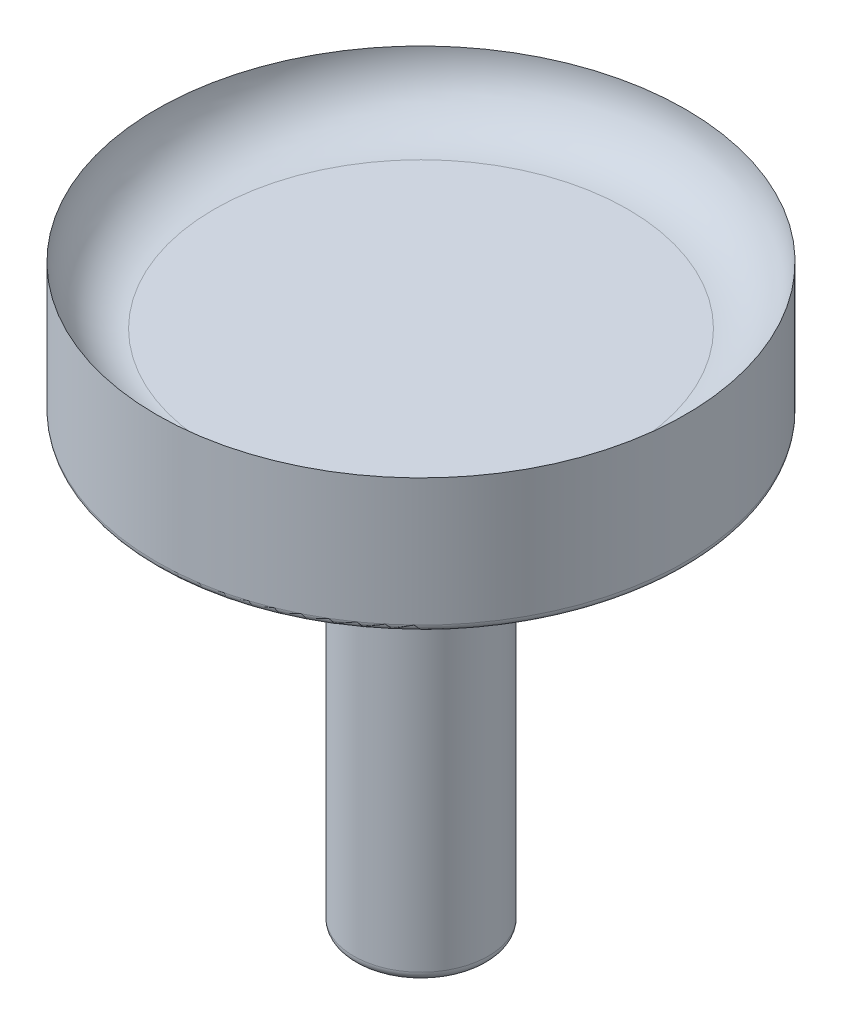
from build123d import *
from build123d.topology import SkipClean

# Parameters (mm, degrees)
CUT_EXTRUDE1_START = 10
CUT_EXTRUDE1_DEPTH = 10
CUT_EXTRUDE2_DEPTH = 70


with BuildPart() as part:
    # Sketch1 → Revolve1 (revolve)
    with BuildSketch(Plane.XY, mode=Mode.PRIVATE) as revolve1_sk:
        with BuildLine():
            Line((-55, 0), (-55, 17.999999999999996))
            ThreePointArc((-55, 17.999999999999996), (-51.48528137423857, 9.514718625761427), (-43, 5.999999999999995))
            Line((-43, 5.999999999999995), (0, 5.999999999999995))
            Line((0, 5.999999999999995), (0, 0))
            Line((0, 0), (0, -2.0000000000000058))
            Line((0, -2.0000000000000058), (-4, -2.000000000000007))
            ThreePointArc((-4, -2.000000000000007), (-8.242640687119284, -3.7573593128807214), (-10.000000000000002, -8.000000000000007))
            Line((-10.000000000000002, -8.000000000000007), (-10.000000000000002, -36.00000000000001))
            ThreePointArc((-10.000000000000002, -36.00000000000001), (-8.242640687119287, -40.24264068711929), (-4, -42.00000000000001))
            Line((-4, -42.00000000000001), (0, -42.00000000000001))
            Line((0, -42.00000000000001), (0, -46.000000000000014))
            Line((0, -46.000000000000014), (-4, -46.000000000000014))
            ThreePointArc((-4, -46.000000000000014), (-8.242640687119284, -47.75735931288073), (-10.000000000000002, -52.000000000000014))
            Line((-10.000000000000002, -52.000000000000014), (-10, -80))
            ThreePointArc((-10, -80), (-8.242640687119286, -84.24264068711929), (-4, -86))
            Line((-4, -86), (4.9e-16, -86))
            Line((4.9e-16, -86), (9.8e-16, -90.00000000000001))
            Line((9.8e-16, -90.00000000000001), (-4.000000000000001, -90.00000000000001))
            ThreePointArc((-4.000000000000001, -90.00000000000001), (-8.242640687119284, -91.75735931288072), (-10, -96.00000000000001))
            Line((-10, -96.00000000000001), (-9.999999999999988, -99.99999999999989))
            ThreePointArc((-9.999999999999988, -99.99999999999989), (-11.999999999999988, -101.99999999999989), (-13.999999999999988, -99.99999999999989))
            Line((-13.999999999999988, -99.99999999999989), (-14, -2.7500000000000058))
            ThreePointArc((-14, -2.7500000000000058), (-14.219669914110089, -2.2196699141100953), (-14.75, -2.0000000000000058))
            Line((-14.75, -2.0000000000000058), (-45.00000000000001, -2.0000000000000053))
            ThreePointArc((-45.00000000000001, -2.0000000000000053), (-49.24264068711929, -3.7573593128807197), (-51.00000000000001, -8.000000000000005))
            Line((-51.00000000000001, -8.000000000000005), (-51.00000000000001, -8.500000000000007))
            ThreePointArc((-51.00000000000001, -8.500000000000007), (-51.439339828220184, -9.560660171779826), (-52.50000000000001, -10.000000000000005))
            Line((-52.50000000000001, -10.000000000000005), (-53.5, -10.000000000000007))
            ThreePointArc((-53.5, -10.000000000000007), (-54.56066017177982, -9.560660171779828), (-55, -8.500000000000007))
            Line((-55, -8.500000000000007), (-55, 0))
        make_face()
    revolve(revolve1_sk.sketch.rotate(Axis((0, -87.52786404500043, 0), (0, 1, 0)), 270), axis=Axis((0, -87.52786404500043, 0), (0, 1, 0)))

    # Sketch3 → Cut-Extrude1 (cut)
    with BuildSketch(Plane(origin=(0, -90, 0), x_dir=(-1, 0, 0), z_dir=(0, -1, 0)).offset(CUT_EXTRUDE1_START)):
        with BuildLine():
            Line((2.0207259421636805, 1.4999999999999996), (8.645808232895293, 1.5000000000000002))
            ThreePointArc((8.645808232895293, 1.5), (9.445113486780746, 1.8990747874226686), (9.606453592105881, 2.7777777777777777))
            ThreePointArc((9.60645359210588, 2.7777777777777772), (4.999999999999978, 8.6602540378444), (-2.397600674429549, 9.708321739928842))
            ThreePointArc((-2.3976006744295484, 9.708321739928842), (-3.0779097337958525, 9.129245614890461), (-3.0238660107710285, 8.237489565935956))
            Line((-3.0238660107710285, 8.237489565935956), (0.2886751345948082, 2.499999999999991))
            ThreePointArc((0.2886751345948091, 2.499999999999992), (1.0207259421636854, 1.767949192431121), (2.0207259421636805, 1.5))
        make_face()
        with BuildLine():
            ThreePointArc((9.606453592105881, -2.7777777777777772), (9.445113486780746, -1.899074787422668), (8.645808232895293, -1.5))
            Line((8.645808232895293, -1.5000000000000002), (2.0207259421636774, -1.5000000000000009))
            ThreePointArc((2.0207259421636774, -1.5000000000000009), (1.020725942163682, -1.7679491924311213), (0.2886751345948062, -2.499999999999993))
            Line((0.28867513459480665, -2.499999999999993), (-3.0238660107710293, -8.23748956593596))
            ThreePointArc((-3.023866010771029, -8.23748956593596), (-3.0779097337958534, -9.129245614890463), (-2.3976006744295493, -9.708321739928842))
            ThreePointArc((-2.397600674429549, -9.708321739928842), (4.999999999999978, -8.6602540378444), (9.60645359210588, -2.7777777777777777))
        make_face()
        with BuildLine():
            Line((-2.3094010767585185, 1.0000000000000089), (-5.621942222124337, 6.737489565935944))
            ThreePointArc((-5.621942222124337, 6.737489565935944), (-6.36720375298497, 7.230170827467779), (-7.208852917676411, 6.9305439621510425))
            ThreePointArc((-7.208852917676411, 6.930543962151044), (-10, 1.22e-15), (-7.208852917676416, -6.93054396215104))
            ThreePointArc((-7.208852917676414, -6.9305439621510425), (-6.367203752984971, -7.230170827467778), (-5.621942222124336, -6.7374895659359435))
            Line((-5.621942222124336, -6.737489565935943), (-2.3094010767585176, -1.000000000000007))
            ThreePointArc((-2.309401076758518, -1.000000000000007), (-2.0414518843273903, 9.4e-16), (-2.309401076758519, 1.000000000000009))
        make_face()
    extrude(amount=-CUT_EXTRUDE1_DEPTH, mode=Mode.SUBTRACT)

    # Sketch3_3 → Cut-Extrude2 (cut)
    with SkipClean():  # the faces are left unmerged after this step: merging them gives an invalid solid
        with BuildSketch(Plane(origin=(0, -90, 0), x_dir=(-1, 0, 0), z_dir=(0, -1, 0))):
            with BuildLine():
                Line((-2.3094010767585185, 1.0000000000000089), (-5.621942222124337, 6.737489565935944))
                ThreePointArc((-5.621942222124337, 6.737489565935944), (-6.36720375298497, 7.230170827467779), (-7.208852917676411, 6.9305439621510425))
                ThreePointArc((-7.208852917676411, 6.930543962151044), (-10, 1.22e-15), (-7.208852917676416, -6.93054396215104))
                ThreePointArc((-7.208852917676414, -6.9305439621510425), (-6.367203752984971, -7.230170827467778), (-5.621942222124336, -6.7374895659359435))
                Line((-5.621942222124336, -6.737489565935943), (-2.3094010767585176, -1.000000000000007))
                ThreePointArc((-2.309401076758518, -1.000000000000007), (-2.0414518843273903, 9.4e-16), (-2.309401076758519, 1.000000000000009))
            make_face()
            with BuildLine():
                ThreePointArc((9.606453592105881, -2.7777777777777772), (9.445113486780746, -1.899074787422668), (8.645808232895293, -1.5))
                Line((8.645808232895293, -1.5000000000000002), (2.0207259421636774, -1.5000000000000009))
                ThreePointArc((2.0207259421636774, -1.5000000000000009), (1.020725942163682, -1.7679491924311213), (0.2886751345948062, -2.499999999999993))
                Line((0.28867513459480665, -2.499999999999993), (-3.0238660107710293, -8.23748956593596))
                ThreePointArc((-3.023866010771029, -8.23748956593596), (-3.0779097337958534, -9.129245614890463), (-2.3976006744295493, -9.708321739928842))
                ThreePointArc((-2.397600674429549, -9.708321739928842), (4.999999999999978, -8.6602540378444), (9.60645359210588, -2.7777777777777777))
            make_face()
            with BuildLine():
                Line((2.0207259421636805, 1.4999999999999996), (8.645808232895293, 1.5000000000000002))
                ThreePointArc((8.645808232895293, 1.5), (9.445113486780746, 1.8990747874226686), (9.606453592105881, 2.7777777777777777))
                ThreePointArc((9.60645359210588, 2.7777777777777772), (4.999999999999978, 8.6602540378444), (-2.397600674429549, 9.708321739928842))
                ThreePointArc((-2.3976006744295484, 9.708321739928842), (-3.0779097337958525, 9.129245614890461), (-3.0238660107710285, 8.237489565935956))
                Line((-3.0238660107710285, 8.237489565935956), (0.2886751345948082, 2.499999999999991))
                ThreePointArc((0.2886751345948091, 2.499999999999992), (1.0207259421636854, 1.767949192431121), (2.0207259421636805, 1.5))
            make_face()
        extrude(amount=-CUT_EXTRUDE2_DEPTH, mode=Mode.SUBTRACT)


solid = part.part
